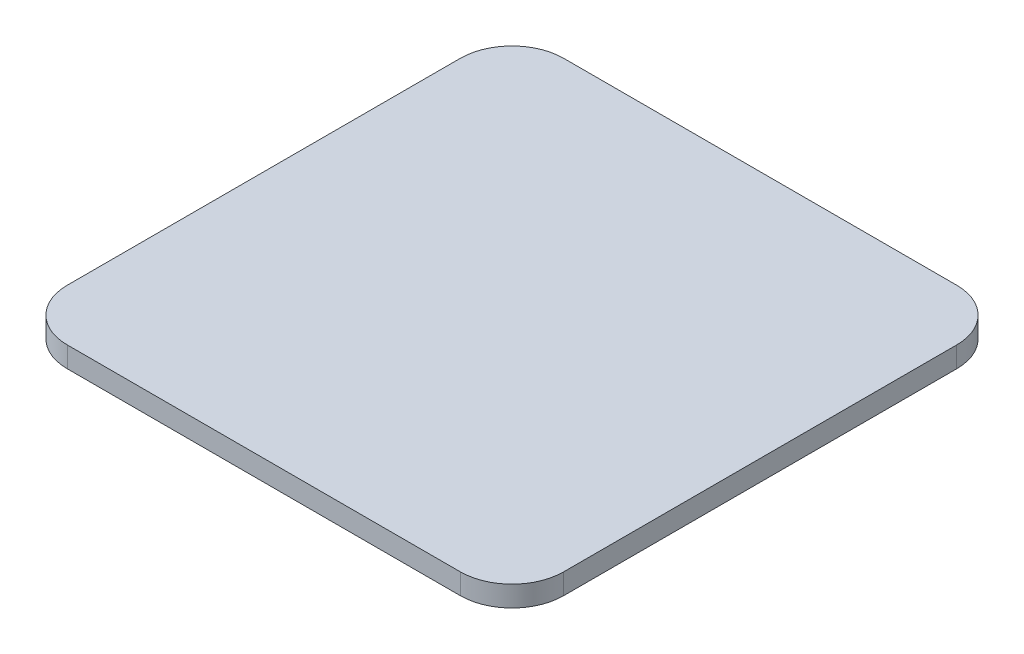
from build123d import *

# Parameters (mm, degrees)
BOSS_EXTRUDE1_DEPTH = 2


with BuildPart() as part:
    # Sketch1 → Boss-Extrude1 (new body)
    with BuildSketch(Plane(origin=(0, 0, 0), x_dir=(1, 0, 0), z_dir=(0, 1, 0))):
        with BuildLine():
            Line((-19, 24), (19, 24))
            ThreePointArc((19, 24), (22.535533906, 22.535533906), (24, 19))
            Line((24, 19), (24, -19))
            ThreePointArc((24, -19), (22.535533906, -22.535533906), (19, -24))
            Line((19, -24), (-19, -24))
            ThreePointArc((-19, -24), (-22.535533906, -22.535533906), (-24, -19))
            Line((-24, -19), (-24, 19))
            ThreePointArc((-24, 19), (-22.535533906, 22.535533906), (-19, 24))
        make_face()
    extrude(amount=BOSS_EXTRUDE1_DEPTH)


solid = part.part
